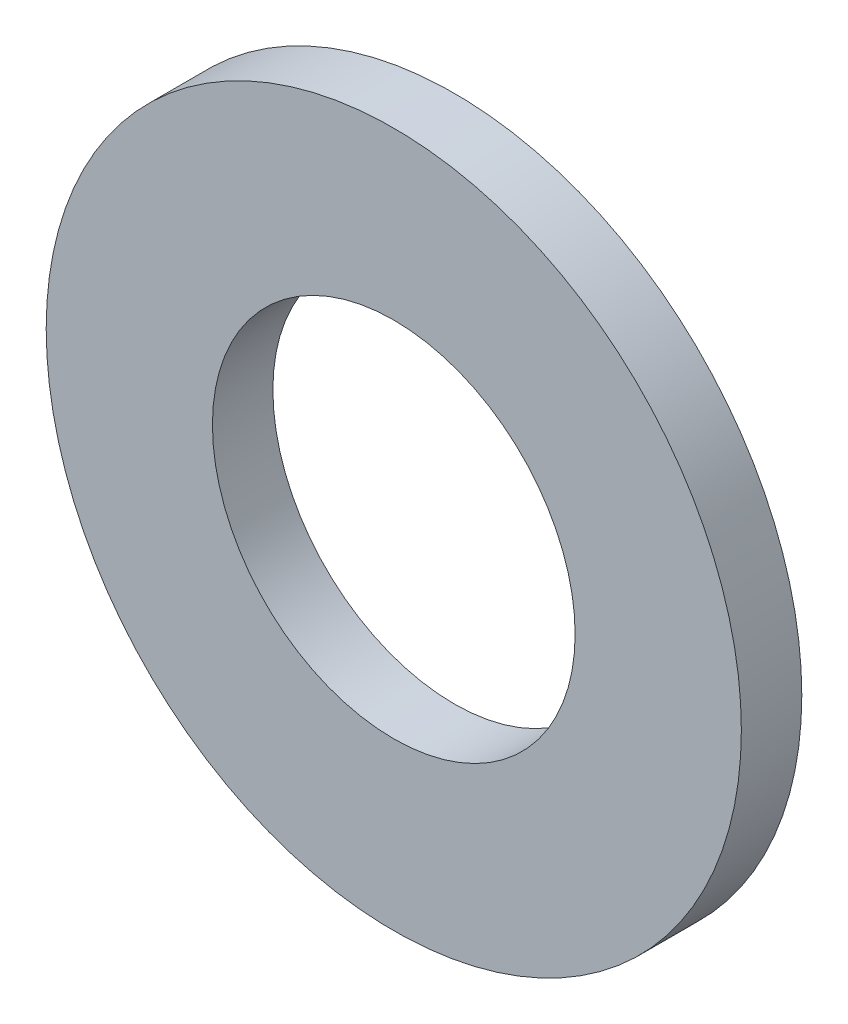
from build123d import *

# Parameters (mm, degrees)
SKETCH1_R           = 11.5
SKETCH1_R_2         = 6
BOSS_EXTRUDE1_DEPTH = 2


with BuildPart() as part:
    # Sketch1 → Boss-Extrude1 (new body)
    with BuildSketch(Plane.XY):
        Circle(SKETCH1_R)
        Circle(SKETCH1_R_2, mode=Mode.SUBTRACT)
    extrude(amount=BOSS_EXTRUDE1_DEPTH)


solid = part.part
